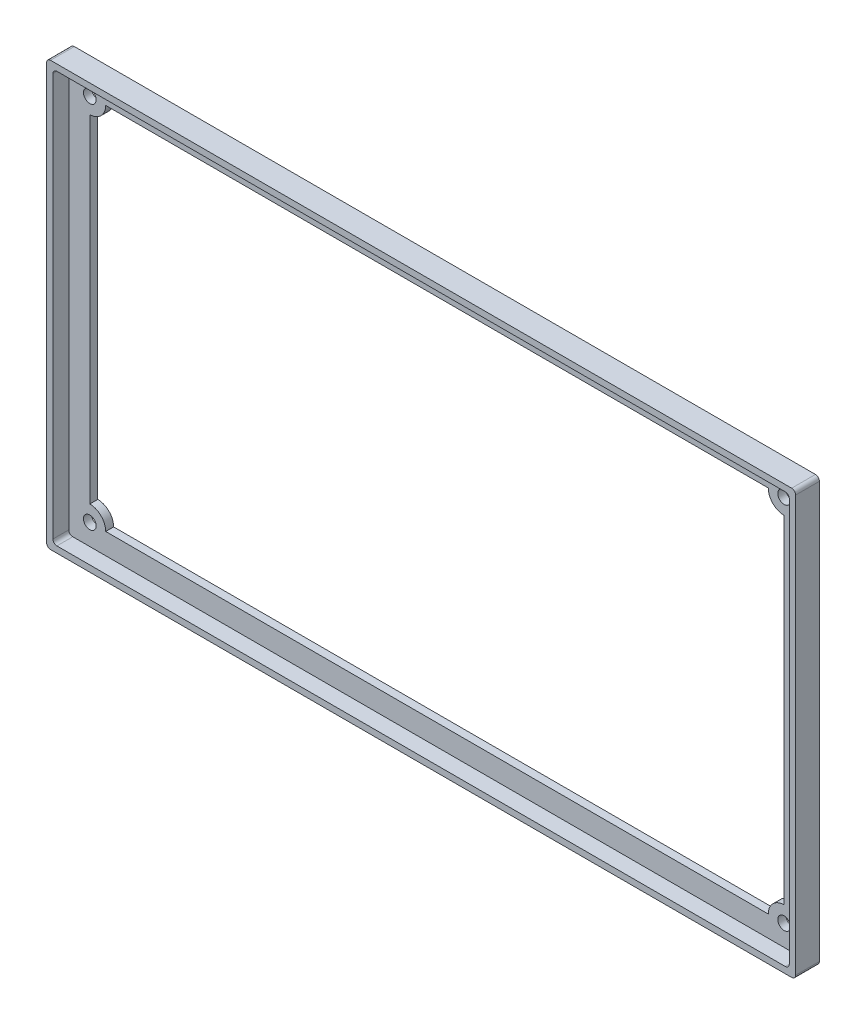
from build123d import *

# Parameters (mm, degrees)
SKETCH_1_W      = 185.6
SKETCH_1_H      = 103.6
SKETCH_1_R      = 1.6
EXTRUDE_1_DEPTH = 2
SKETCH_1_3_W    = 188.8
SKETCH_1_3_H    = 106.8
SKETCH_1_3_W_2  = 185.6
SKETCH_1_3_H_2  = 103.6
EXTRUDE_2_DEPTH = 6
FILLET_1_R      = 1


with BuildPart() as part:
    # Эскиз1 → Бобышка-Вытянуть1 (new body)
    with BuildSketch(Plane.XY):
        with Locations((94.4, 53.4)):
            Rectangle(SKETCH_1_W, SKETCH_1_H)
        with BuildLine():
            ThreePointArc((177.9, 99.9), (179.071572875, 97.071572875), (181.9, 95.9))
            Line((181.9, 95.9), (181.9, 10.9))
            ThreePointArc((181.9, 10.9), (179.071572875, 9.728427125), (177.9, 6.9))
            Line((177.9, 6.9), (10.9, 6.9))
            ThreePointArc((10.9, 6.9), (9.728427125, 9.728427125), (6.9, 10.9))
            Line((6.9, 10.9), (6.9, 95.9))
            ThreePointArc((6.9, 95.9), (9.728427125, 97.071572875), (10.9, 99.9))
            Line((10.9, 99.9), (177.9, 99.9))
        make_face(mode=Mode.SUBTRACT)
        with Locations((181.9, 99.9)):
            Circle(SKETCH_1_R, mode=Mode.SUBTRACT)
        with Locations((181.9, 6.9)):
            Circle(SKETCH_1_R, mode=Mode.SUBTRACT)
        with Locations((6.9, 99.9)):
            Circle(SKETCH_1_R, mode=Mode.SUBTRACT)
        with Locations((6.9, 6.9)):
            Circle(SKETCH_1_R, mode=Mode.SUBTRACT)
    extrude(amount=EXTRUDE_1_DEPTH)

    # Эскиз1<3> → Бобышка-Вытянуть2 (add)
    with BuildSketch(Plane.XY):
        with Locations((94.4, 53.4)):
            Rectangle(SKETCH_1_3_W, SKETCH_1_3_H)
        with Locations((94.4, 53.4)):
            Rectangle(SKETCH_1_3_W_2, SKETCH_1_3_H_2, mode=Mode.SUBTRACT)
    extrude(amount=EXTRUDE_2_DEPTH)

    # Скругление1
    fillet_1_edges = [part.edges().sort_by_distance(p)[0] for p in [
        (0, 0, 3),
        (188.8, 0, 3),
        (188.8, 106.8, 3),
        (0, 106.8, 3),
        (1.6, 105.2, 4),
        (1.6, 1.6, 4),
        (187.2, 1.6, 4),
        (187.2, 105.2, 4),
    ]]
    fillet(fillet_1_edges, radius=FILLET_1_R)


solid = part.part
